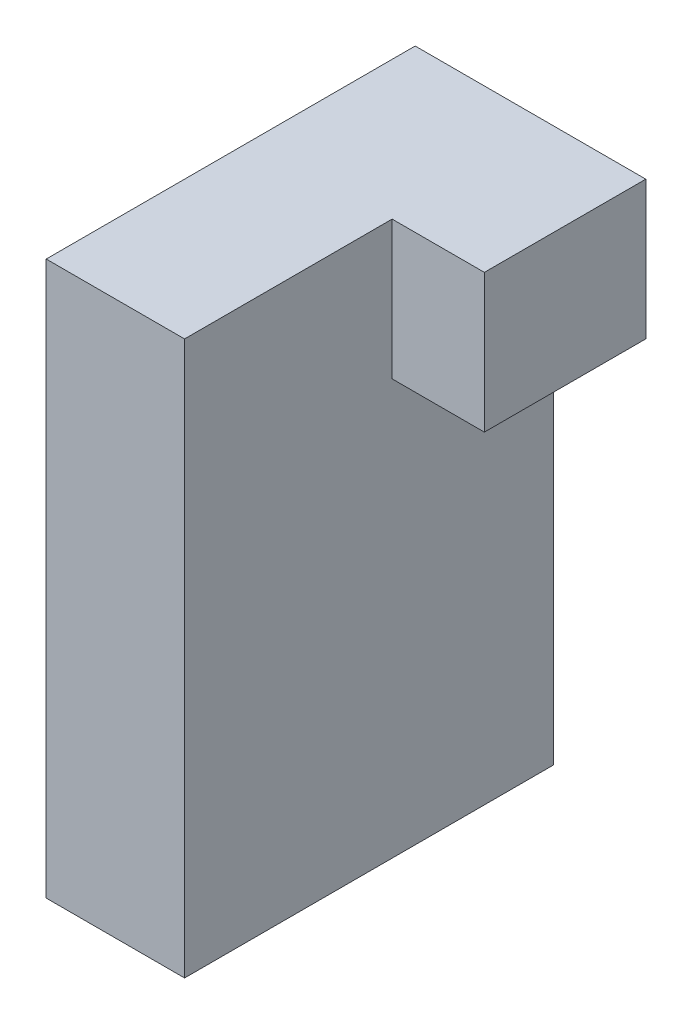
from build123d import *

# Parameters (mm, degrees)
SKETCH1_W           = 50.8
SKETCH1_H           = 76.2
BOSS_EXTRUDE1_DEPTH = 9.525
SKETCH2_W           = 22.225
SKETCH2_H           = 19.05
BOSS_EXTRUDE2_DEPTH = 12.7


with BuildPart() as part:
    # Sketch1 → Boss-Extrude1 (new body, symmetric)
    with BuildSketch(Plane(origin=(0, 0, 0), x_dir=(0, 0, -1), z_dir=(1, 0, 0))):
        Rectangle(SKETCH1_W, SKETCH1_H)
    extrude(amount=BOSS_EXTRUDE1_DEPTH, both=True)

    # Sketch2 → Boss-Extrude2 (add)
    with BuildSketch(Plane(origin=(9.525, 0, 0), x_dir=(0, 0, -1), z_dir=(1, 0, 0))):
        with Locations((14.2875, 28.575)):
            Rectangle(SKETCH2_W, SKETCH2_H)
    extrude(amount=BOSS_EXTRUDE2_DEPTH)


solid = part.part
